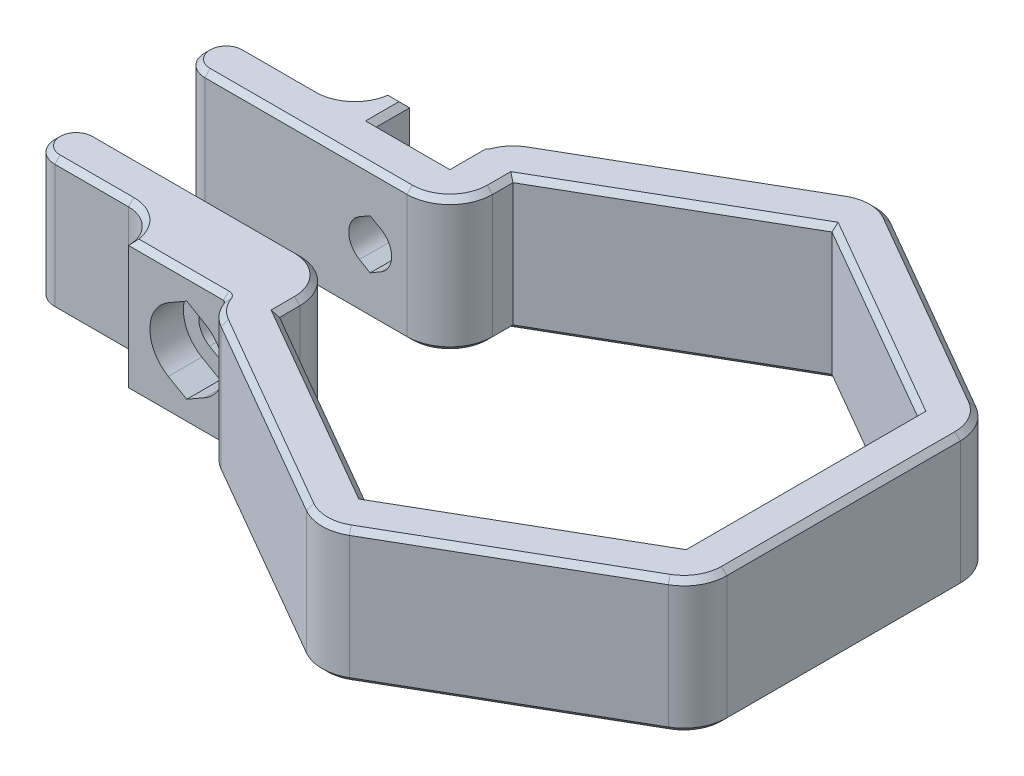
from build123d import *

# Parameters (mm, degrees)
BOSS_EXTRUDE1_DEPTH = 10
SKETCH3_W           = 5.5
SKETCH3_H           = 10
CUT_EXTRUDE1_DEPTH  = 2.5
CUT_EXTRUDE2_DEPTH  = 28.83597813
CUT_EXTRUDE3_DEPTH  = 2.5
CHAMFER1_SIZE       = 0.4


with BuildPart() as part:
    # Sketch1 → Boss-Extrude1 (new body)
    with BuildSketch(Plane(origin=(0, 0, 0), x_dir=(1, 0, 0), z_dir=(0, 1, 0))):
        with BuildLine():
            Line((15.1, -8.717989065), (15.1, 8.717989065))
            Line((15.1, 8.717989065), (0, 17.43597813))
            Line((0, 17.43597813), (-15.1, 8.717989065))
            Line((-15.1, 8.717989065), (-15.1, 7.2))
            ThreePointArc((-15.1, 7.2), (-16.0372583, 4.9372583), (-18.3, 4))
            Line((-18.3, 4), (-33.4, 4))
            ThreePointArc((-33.4, 4), (-35, 5.6), (-33.4, 7.2))
            Line((-33.4, 7.2), (-27.9, 7.2))
            ThreePointArc((-27.9, 7.2), (-26.132233047, 7.932233047), (-25.4, 9.7))
            Line((-25.4, 9.7), (-18.3, 9.7))
            ThreePointArc((-18.3, 9.7), (-18.176160108, 9.73872205), (-18.096437184, 9.841093781))
            ThreePointArc((-18.096437184, 9.841093781), (-17.541501628, 10.786580324), (-16.7, 11.489270357))
            Line((-16.7, 11.489270357), (-1.6, 20.207259422))
            ThreePointArc((-1.6, 20.207259422), (0, 20.63597813), (1.6, 20.207259422))
            Line((1.6, 20.207259422), (16.7, 11.489270357))
            ThreePointArc((16.7, 11.489270357), (17.871281292, 10.317989065), (18.3, 8.717989065))
            Line((18.3, 8.717989065), (18.3, -8.717989065))
            ThreePointArc((18.3, -8.717989065), (17.871281292, -10.317989065), (16.7, -11.489270357))
            Line((16.7, -11.489270357), (1.6, -20.207259422))
            ThreePointArc((1.6, -20.207259422), (0, -20.63597813), (-1.6, -20.207259422))
            Line((-1.6, -20.207259422), (-16.7, -11.489270357))
            ThreePointArc((-16.7, -11.489270357), (-17.541501628, -10.786580324), (-18.096437184, -9.841093781))
            ThreePointArc((-18.096437184, -9.841093781), (-18.176160108, -9.73872205), (-18.3, -9.7))
            Line((-18.3, -9.7), (-25.4, -9.7))
            ThreePointArc((-25.4, -9.7), (-26.132233047, -7.932233047), (-27.9, -7.2))
            Line((-27.9, -7.2), (-33.4, -7.2))
            ThreePointArc((-33.4, -7.2), (-35, -5.6), (-33.4, -4))
            Line((-33.4, -4), (-18.3, -4))
            ThreePointArc((-18.3, -4), (-16.0372583, -4.9372583), (-15.1, -7.2))
            Line((-15.1, -7.2), (-15.1, -8.717989065))
            Line((-15.1, -8.717989065), (0, -17.43597813))
            Line((0, -17.43597813), (15.1, -8.717989065))
        make_face()
    extrude(amount=BOSS_EXTRUDE1_DEPTH)

    # Sketch3 → Cut-Extrude1 (cut)
    with BuildSketch(Plane(origin=(0, 0, -9.7), x_dir=(-1, 0, 0), z_dir=(0, 0, -1))):
        with Locations((21.05, 5)):
            Rectangle(SKETCH3_W, SKETCH3_H)
    extrude(amount=-CUT_EXTRUDE1_DEPTH, mode=Mode.SUBTRACT)

    # Sketch4 → Cut-Extrude2 (cut, through all)
    with BuildSketch(Plane(origin=(0, 0, -7.2), x_dir=(-1, 0, 0), z_dir=(0, 0, -1))):
        with BuildLine():
            Line((20.25, 6.385640646), (21.05, 6.847520861))
            Line((21.05, 6.847520861), (21.85, 6.385640646))
            ThreePointArc((21.85, 6.385640646), (22.65, 5), (21.85, 3.614359354))
            Line((21.85, 3.614359354), (21.05, 3.152479139))
            Line((21.05, 3.152479139), (20.25, 3.614359354))
            ThreePointArc((20.25, 3.614359354), (19.45, 5), (20.25, 6.385640646))
        make_face()
    extrude(amount=-CUT_EXTRUDE2_DEPTH, mode=Mode.SUBTRACT)

    # Sketch5 → Cut-Extrude3 (cut)
    with BuildSketch(Plane.XY.offset(9.7)):
        with BuildLine():
            Line((-22.425, 2.61843014), (-21.05, 1.824573519))
            Line((-21.05, 1.824573519), (-19.675, 2.61843014))
            ThreePointArc((-19.675, 2.61843014), (-18.3, 5), (-19.675, 7.38156986))
            Line((-19.675, 7.38156986), (-21.05, 8.175426481))
            Line((-21.05, 8.175426481), (-22.425, 7.38156986))
            ThreePointArc((-22.425, 7.38156986), (-23.8, 5), (-22.425, 2.61843014))
        make_face()
    extrude(amount=-CUT_EXTRUDE3_DEPTH, mode=Mode.SUBTRACT)

    # Chamfer1
    chamfer1_edges = [part.edges().sort_by_distance(p)[0] for p in [
        (-30.65, 10, -7.2),
        (-35, 10, -5.6),
        (-25.85, 10, -4),
        (-16.0372583, 10, -4.9372583),
        (-15.1, 10, -7.958994532),
        (-7.55, 10, -13.076983597),
        (7.55, 10, -13.076983597),
        (15.1, 10, 0),
        (-15.1, 10, 7.958994532),
        (-16.0372583, 10, 4.9372583),
        (-25.85, 10, 4),
        (-35, 10, 5.6),
        (-30.65, 10, 7.2),
        (15.1, 0, 0),
        (7.55, 0, -13.076983597),
        (-7.55, 0, -13.076983597),
        (-15.1, 0, -7.958994532),
        (-16.0372583, 0, -4.9372583),
        (-25.85, 0, -4),
        (-35, 0, -5.6),
        (-26.132233047, 10, 7.932233047),
        (-30.65, 0, -7.2),
        (-26.132233047, 0, -7.932233047),
        (-18.176160108, 0, -9.73872205),
        (-17.541501628, 0, -10.786580324),
        (-9.15, 0, -15.848264889),
        (0, 0, -20.63597813),
        (9.15, 0, -15.848264889),
        (17.871281292, 0, -10.317989065),
        (18.3, 0, 0),
        (-21.85, 10, 9.7),
        (17.871281292, 0, 10.317989065),
        (9.15, 0, 15.848264889),
        (0, 0, 20.63597813),
        (-9.15, 0, 15.848264889),
        (-17.541501628, 0, 10.786580324),
        (-18.176160108, 0, 9.73872205),
        (-21.85, 0, 9.7),
        (-26.132233047, 0, 7.932233047),
        (-30.65, 0, 7.2),
        (-35, 0, 5.6),
        (-18.176160108, 10, 9.73872205),
        (-25.85, 0, 4),
        (-16.0372583, 0, 4.9372583),
        (-15.1, 0, 7.958994532),
        (-7.55, 0, 13.076983597),
        (7.55, 0, 13.076983597),
        (-17.541501628, 10, 10.786580324),
        (-9.15, 10, 15.848264889),
        (7.55, 10, 13.076983597),
        (0, 10, 20.63597813),
        (9.15, 10, 15.848264889),
        (17.871281292, 10, 10.317989065),
        (18.3, 10, 0),
        (17.871281292, 10, -10.317989065),
        (9.15, 10, -15.848264889),
        (0, 10, -20.63597813),
        (-9.15, 10, -15.848264889),
        (-17.541501628, 10, -10.786580324),
        (-18.176160108, 10, -9.73872205),
        (-7.55, 10, 13.076983597),
        (-24.6, 0, -9.7),
        (-24.6, 10, -9.7),
        (-18.3, 0, -8.45),
        (-21.05, 10, -7.2),
        (-18.3, 10, -8.45),
        (-23.8, 10, -8.45),
        (-21.05, 0, -7.2),
        (-23.8, 0, -8.45),
        (-26.132233047, 10, -7.932233047),
    ]]
    chamfer(chamfer1_edges, length=CHAMFER1_SIZE)


solid = part.part
